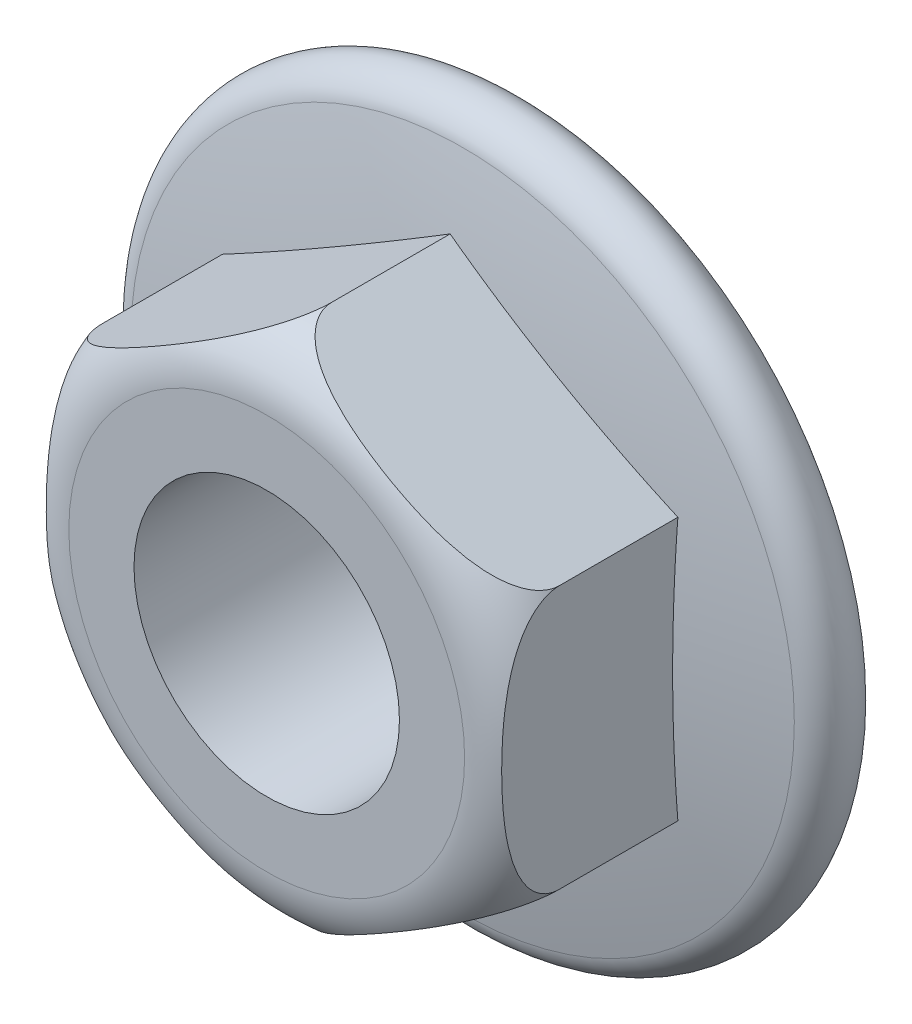
from build123d import *

# Parameters (mm, degrees)
HEAD_DEPTH         = 4
HOLE_SKETCH_R      = 2.04
THROUGH_HOLE_DEPTH = 5


with BuildPart() as part:
    # Head Sketch → Head (new body)
    with BuildSketch(Plane.XY):
        Polygon((0, 4.041451884), (3.5, 2.020725942), (3.5, -2.020725942), (0, -4.041451884), (-3.5, -2.020725942), (-3.5, 2.020725942), align=None)
    extrude(amount=HEAD_DEPTH)

    # Flange Sketch → Flange (revolve)
    with BuildSketch(Plane(origin=(0, 0, 0), x_dir=(-1, 0, 0), z_dir=(0, 1, 0))):
        with BuildLine():
            Line((-5, 0), (0, 0))
            Line((0, 0), (0, 1.5))
            ThreePointArc((0, 1.5), (-2.562220765, 1.372207648), (-5.099009901, 0.99009901))
            ThreePointArc((-5.099009901, 0.99009901), (-5.497518595, 0.45024814), (-5, 0))
        make_face()
    revolve(axis=Axis((0, 0, 1.843425858), (0, 0, -1)))

    # Sketch5 → Head Trim (revolve, cut)
    with BuildSketch(Plane(origin=(0, 0, 0), x_dir=(0, 0, -1), z_dir=(1, 0, 0))):
        with BuildLine():
            Line((-4, -3.041451884), (-4, -4.041451884))
            Line((-4, -4.041451884), (-3, -4.041451884))
            ThreePointArc((-3, -4.041451884), (-3.707106781, -3.748558666), (-4, -3.041451884))
        make_face()
    revolve(axis=Axis((0, 0, 15.085599173), (0, 0, -1)), mode=Mode.SUBTRACT)

    # Hole Sketch → Through Hole (cut, through all)
    with BuildSketch(Plane.XY.offset(4)):
        Circle(HOLE_SKETCH_R)
    extrude(amount=-THROUGH_HOLE_DEPTH, mode=Mode.SUBTRACT)


solid = part.part
